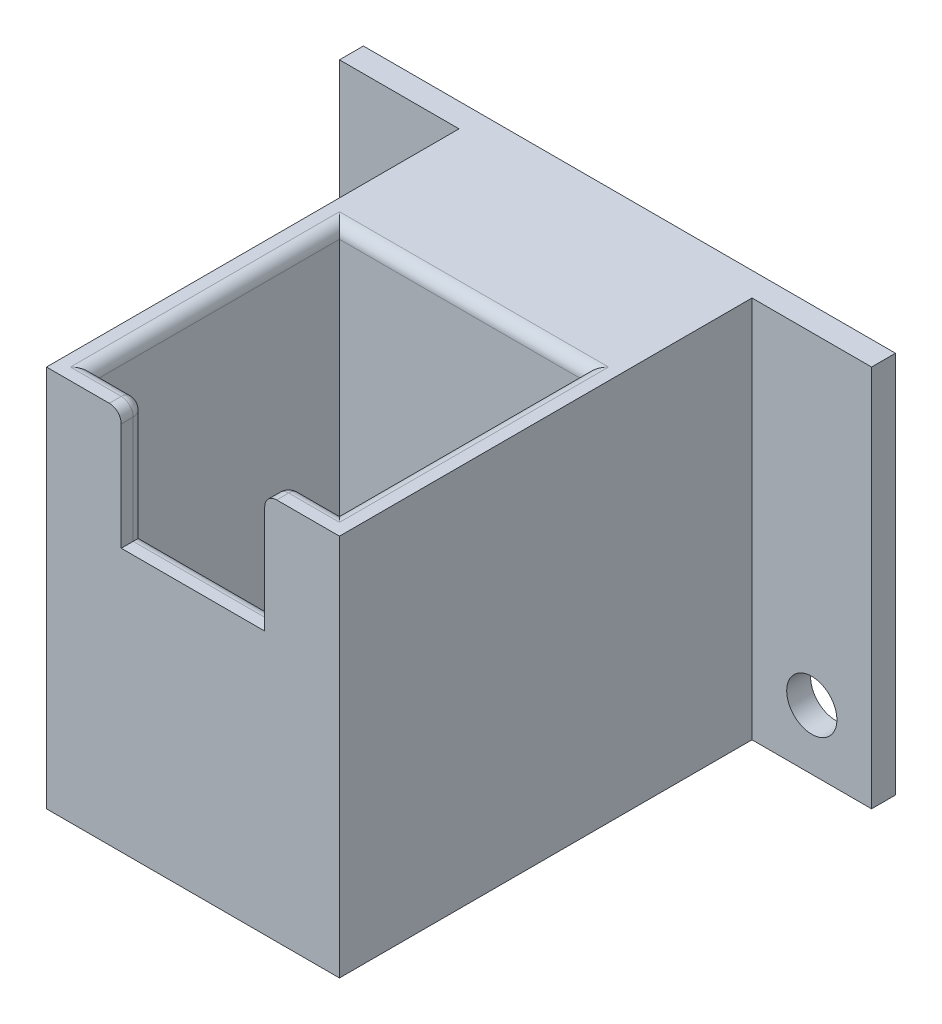
from build123d import *

# Parameters (mm, degrees)
ESQUISSE1_W             = 20.5
ESQUISSE1_H             = 20.5
BOSS_EXTRU_1_DEPTH      = 32
ESQUISSE2_W             = 20.5
ESQUISSE2_H             = 20.5
ESQUISSE2_R             = 8
ESQUISSE2_R_2           = 1.25
BOSS_EXTRU_2_DEPTH      = 2
ESQUISSE4_W             = 12
ESQUISSE4_H             = 2
ENL_V_MAT_EXTRU_2_DEPTH = 10
CONG_1_R                = 1
ENL_V_MAT_EXTRU_3_REACH = 38.5
ESQUISSE5_R             = 2.1


with BuildPart() as part:
    # Esquisse1 → Boss.-Extru.1 (new body)
    with BuildSketch(Plane(origin=(0, 0, 0), x_dir=(1, 0, 0), z_dir=(0, 1, 0))):
        Polygon((0, 0), (24.5, 0), (24.5, 34.5), (34.5, 34.5), (34.5, 36.5), (24.5, 36.5), (0, 36.5), (-10, 36.5), (-10, 34.5), (0, 34.5), align=None)
        with Locations((12.25, 12.25)):
            Rectangle(ESQUISSE1_W, ESQUISSE1_H, mode=Mode.SUBTRACT)
    extrude(amount=BOSS_EXTRU_1_DEPTH)

    # Esquisse2 → Boss.-Extru.2 (add)
    with BuildSketch(Plane.XZ):
        with Locations((12.25, -12.25)):
            Rectangle(ESQUISSE2_W, ESQUISSE2_H)
        with Locations((12.25, -12.25)):
            Circle(ESQUISSE2_R, mode=Mode.SUBTRACT)
        with Locations((3.5, -3.5)):
            Circle(ESQUISSE2_R_2, mode=Mode.SUBTRACT)
        with Locations((21, -3.5)):
            Circle(ESQUISSE2_R_2, mode=Mode.SUBTRACT)
        with Locations((21, -21)):
            Circle(ESQUISSE2_R_2, mode=Mode.SUBTRACT)
        with Locations((3.5, -21)):
            Circle(ESQUISSE2_R_2, mode=Mode.SUBTRACT)
    extrude(amount=-BOSS_EXTRU_2_DEPTH)

    # Esquisse4 → Enlèv. mat.-Extru.2 (cut)
    with BuildSketch(Plane(origin=(0, 32, 0), x_dir=(1, 0, 0), z_dir=(0, 1, 0))):
        with Locations((12.25, 1)):
            Rectangle(ESQUISSE4_W, ESQUISSE4_H)
    extrude(amount=-ENL_V_MAT_EXTRU_2_DEPTH, mode=Mode.SUBTRACT)

    # Congé1
    cong_1_edges = [part.edges().sort_by_distance(p)[0] for p in [
        (2, 32, -12.25),
        (4.125, 32, -2),
        (22.5, 32, -12.25),
        (12.25, 32, -22.5),
        (20.375, 32, -2),
        (12.25, 22, -2),
        (6.25, 27, -2),
        (18.25, 27, -2),
        (6.25, 32, -1),
        (18.25, 32, -1),
    ]]
    fillet(cong_1_edges, radius=CONG_1_R)

    # Esquisse5 → Enlèv. mat.-Extru.3 (cut, up to next)
    with BuildSketch(Plane(origin=(0, 0, -36.5), x_dir=(-1, 0, 0), z_dir=(0, 0, -1)), mode=Mode.PRIVATE) as enl_v_mat_extru_3_sk1:
        with Locations((-29.5, 5)):
            Circle(ESQUISSE5_R)
    enl_v_mat_extru_3_tool1 = extrude(enl_v_mat_extru_3_sk1.sketch, amount=-ENL_V_MAT_EXTRU_3_REACH, mode=Mode.PRIVATE) & part.part
    add(enl_v_mat_extru_3_tool1.solids().sort_by_distance((29.5, 5, -36.5))[0], mode=Mode.SUBTRACT)
    # Esquisse5 → Enlèv. mat.-Extru.3 (cut, up to next)
    with BuildSketch(Plane(origin=(0, 0, -36.5), x_dir=(-1, 0, 0), z_dir=(0, 0, -1)), mode=Mode.PRIVATE) as enl_v_mat_extru_3_sk2:
        with Locations((5, 5)):
            Circle(ESQUISSE5_R)
    enl_v_mat_extru_3_tool2 = extrude(enl_v_mat_extru_3_sk2.sketch, amount=-ENL_V_MAT_EXTRU_3_REACH, mode=Mode.PRIVATE) & part.part
    add(enl_v_mat_extru_3_tool2.solids().sort_by_distance((-5, 5, -36.5))[0], mode=Mode.SUBTRACT)


solid = part.part
